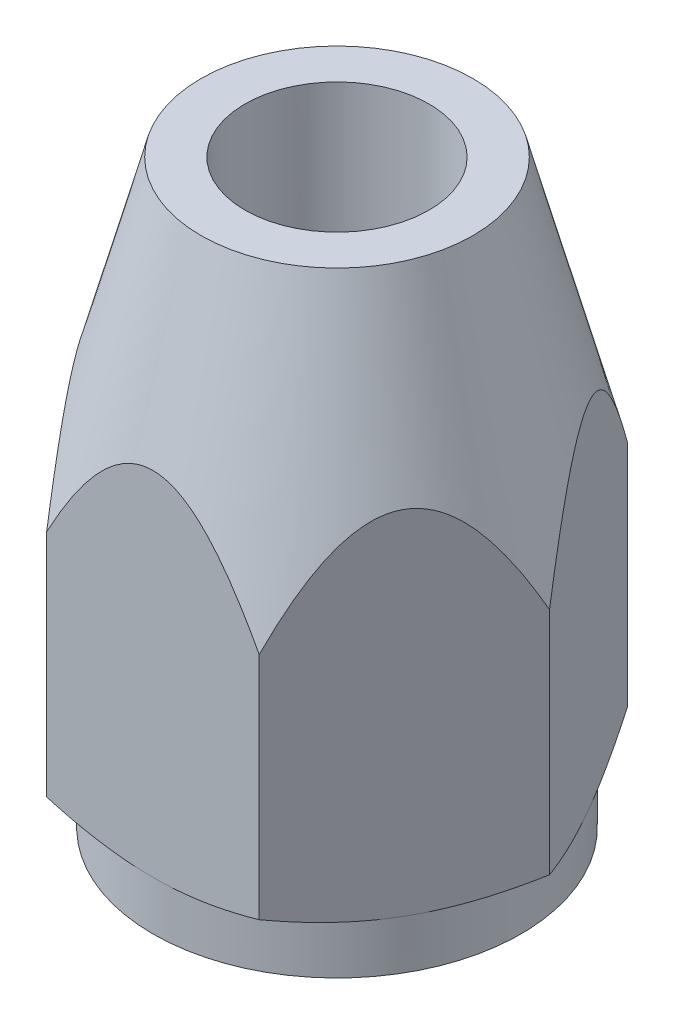
from build123d import *

# Parameters (mm, degrees)
BOSS_EXTRUDE1_DEPTH = 14.2
SKETCH2_R           = 2.25
CUT_EXTRUDE1_DEPTH  = 15.2
SKETCH3_R           = 3.95
CUT_EXTRUDE2_DEPTH  = 10
SKETCH4_OUTSIDE_W   = 21.704
SKETCH4_OUTSIDE_H   = 20.312
SKETCH4_OUTSIDE_R   = 3.325
CUT_EXTRUDE3_DEPTH  = 10
CUT_EXTRUDE3_TAPER  = 15
SKETCH5_OUTSIDE_W   = 16.344
SKETCH5_OUTSIDE_H   = 14.952
SKETCH5_OUTSIDE_R   = 4.5
CUT_EXTRUDE4_DEPTH  = 1.2
SKETCH6_OUTSIDE_W   = 50.986
SKETCH6_OUTSIDE_H   = 49.594
SKETCH6_OUTSIDE_R   = 4.5
CUT_EXTRUDE5_DEPTH  = 10
CUT_EXTRUDE5_TAPER  = 60


with BuildPart() as part:
    # Sketch1 → Boss-Extrude1 (new body)
    with BuildSketch(Plane(origin=(0, 0, 0), x_dir=(1, 0, 0), z_dir=(0, 1, 0))):
        Polygon((-2.598076211, -4.5), (2.598076211, -4.5), (5.196152423, 0), (2.598076211, 4.5), (-2.598076211, 4.5), (-5.196152423, 0), align=None)
    extrude(amount=BOSS_EXTRUDE1_DEPTH)

    # Sketch2 → Cut-Extrude1 (cut, through all)
    with BuildSketch(Plane(origin=(0, 14.2, 0), x_dir=(1, 0, 0), z_dir=(0, 1, 0))):
        Circle(SKETCH2_R)
    extrude(amount=-CUT_EXTRUDE1_DEPTH, mode=Mode.SUBTRACT)

    # Sketch3 → Cut-Extrude2 (cut)
    with BuildSketch(Plane.XZ):
        Circle(SKETCH3_R)
    extrude(amount=-CUT_EXTRUDE2_DEPTH, mode=Mode.SUBTRACT)

    # Sketch4 outside → Cut-Extrude3 (cut)
    with BuildSketch(Plane(origin=(0, 14.2, 0), x_dir=(1, 0, 0), z_dir=(0, 1, 0))):
        Rectangle(SKETCH4_OUTSIDE_W, SKETCH4_OUTSIDE_H)
        Circle(SKETCH4_OUTSIDE_R, mode=Mode.SUBTRACT)
    extrude(amount=-CUT_EXTRUDE3_DEPTH, taper=CUT_EXTRUDE3_TAPER, mode=Mode.SUBTRACT)

    # Sketch5 outside → Cut-Extrude4 (cut)
    with BuildSketch(Plane.XZ):
        Rectangle(SKETCH5_OUTSIDE_W, SKETCH5_OUTSIDE_H)
        Circle(SKETCH5_OUTSIDE_R, mode=Mode.SUBTRACT)
    extrude(amount=-CUT_EXTRUDE4_DEPTH, mode=Mode.SUBTRACT)

    # Sketch6 outside → Cut-Extrude5 (cut)
    with BuildSketch(Plane.XZ.offset(-1.2)):
        Rectangle(SKETCH6_OUTSIDE_W, SKETCH6_OUTSIDE_H)
        Circle(SKETCH6_OUTSIDE_R, mode=Mode.SUBTRACT)
    extrude(amount=-CUT_EXTRUDE5_DEPTH, taper=CUT_EXTRUDE5_TAPER, mode=Mode.SUBTRACT)


solid = part.part
